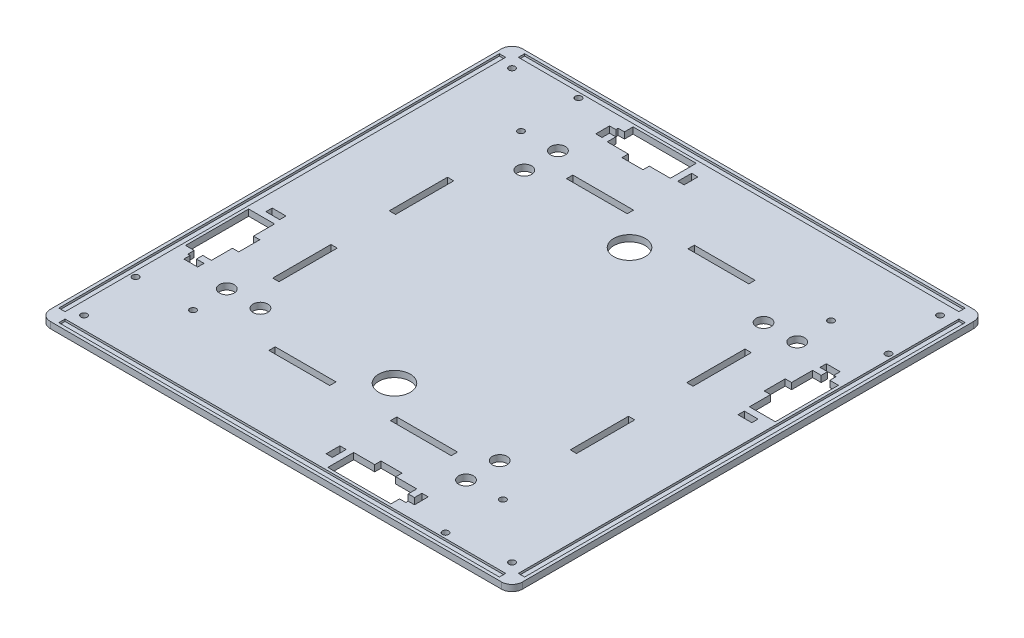
from build123d import *

# Parameters (mm, degrees)
SKETCH1_W           = 224.4
SKETCH1_H           = 224.4
SKETCH1_R           = 1.5
SKETCH1_W_2         = 28.88
SKETCH1_H_2         = 3
SKETCH1_W_3         = 3
SKETCH1_H_3         = 27.68
BOSS_EXTRUDE1_DEPTH = 3
FILLET1_R           = 5
SKETCH2_W           = 209.4
SKETCH2_H           = 3
SKETCH2_W_2         = 3
SKETCH2_H_2         = 209.4
CUT_EXTRUDE1_DEPTH  = 1
CUT_EXTRUDE3_DEPTH  = 4
CUT_EXTRUDE4_REACH  = 5
SKETCH4_R           = 1.5
SKETCH5_W           = 3
SKETCH5_H           = 6.55
SKETCH5_W_2         = 6.55
SKETCH5_H_2         = 3
CUT_EXTRUDE5_DEPTH  = 4
SKETCH6_R           = 3.5
CUT_EXTRUDE6_DEPTH  = 4
SKETCH13_R          = 7.5
CUT_EXTRUDE10_DEPTH = 4


with BuildPart() as part:
    # Sketch1 → Boss-Extrude1 (new body)
    with BuildSketch(Plane(origin=(0, 0, 0), x_dir=(1, 0, 0), z_dir=(0, 1, 0))):
        with Locations((112.2, 112.2)):
            Rectangle(SKETCH1_W, SKETCH1_H)
        with Locations((213.9, 10.5)):
            Circle(SKETCH1_R, mode=Mode.SUBTRACT)
        with Locations((213.9, 213.9)):
            Circle(SKETCH1_R, mode=Mode.SUBTRACT)
        with Locations((10.5, 10.5)):
            Circle(SKETCH1_R, mode=Mode.SUBTRACT)
        with Locations((10.5, 213.9)):
            Circle(SKETCH1_R, mode=Mode.SUBTRACT)
        with Locations((83.32, 41.5)):
            Rectangle(SKETCH1_W_2, SKETCH1_H_2, mode=Mode.SUBTRACT)
        with Locations((141.08, 41.5)):
            Rectangle(SKETCH1_W_2, SKETCH1_H_2, mode=Mode.SUBTRACT)
        with Locations((141.08, 182.9)):
            Rectangle(SKETCH1_W_2, SKETCH1_H_2, mode=Mode.SUBTRACT)
        with Locations((83.32, 182.9)):
            Rectangle(SKETCH1_W_2, SKETCH1_H_2, mode=Mode.SUBTRACT)
        with Locations((41.5, 84.52)):
            Rectangle(SKETCH1_W_3, SKETCH1_H_3, mode=Mode.SUBTRACT)
        with Locations((41.5, 139.88)):
            Rectangle(SKETCH1_W_3, SKETCH1_H_3, mode=Mode.SUBTRACT)
        with Locations((182.9, 139.88)):
            Rectangle(SKETCH1_W_3, SKETCH1_H_3, mode=Mode.SUBTRACT)
        with Locations((182.9, 84.52)):
            Rectangle(SKETCH1_W_3, SKETCH1_H_3, mode=Mode.SUBTRACT)
    extrude(amount=BOSS_EXTRUDE1_DEPTH)

    # Fillet1
    fillet1_edges = [part.edges().sort_by_distance(p)[0] for p in [
        (0, 1.5, -224.4),
        (224.4, 1.5, -224.4),
        (224.4, 1.5, 0),
        (0, 1.5, 0),
    ]]
    fillet(fillet1_edges, radius=FILLET1_R)

    # Sketch2 → Cut-Extrude1 (cut)
    with BuildSketch(Plane(origin=(0, 3, 0), x_dir=(1, 0, 0), z_dir=(0, 1, 0))):
        with Locations((112.2, 3)):
            Rectangle(SKETCH2_W, SKETCH2_H)
        with Locations((221.4, 112.2)):
            Rectangle(SKETCH2_W_2, SKETCH2_H_2)
        with Locations((112.2, 221.4)):
            Rectangle(SKETCH2_W, SKETCH2_H)
        with Locations((3, 112.2)):
            Rectangle(SKETCH2_W_2, SKETCH2_H_2)
    extrude(amount=-CUT_EXTRUDE1_DEPTH, mode=Mode.SUBTRACT)

    # Sketch3 → Cut-Extrude3 (cut, through all)
    with BuildSketch(Plane(origin=(0, 3, 0), x_dir=(1, 0, 0), z_dir=(0, 1, 0))):
        Polygon((131, 18.15), (131, 5.85), (161, 5.85), (161, 9.95), (164, 9.95), (164, 14.05), (161, 14.05), (161, 18.15), (151, 18.15), (151, 21.15), (141, 21.15), (141, 18.15), align=None)
        Polygon((18.15, 93.4), (5.85, 93.4), (5.85, 63.4), (9.95, 63.4), (9.95, 60.4), (14.05, 60.4), (14.05, 63.4), (18.15, 63.4), (18.15, 73.4), (21.15, 73.4), (21.15, 83.4), (18.15, 83.4), align=None)
        Polygon((93.4, 206.25), (93.4, 218.55), (63.4, 218.55), (63.4, 214.45), (60.4, 214.45), (60.4, 210.35), (63.4, 210.35), (63.4, 206.25), (73.4, 206.25), (73.4, 203.25), (83.4, 203.25), (83.4, 206.25), align=None)
        Polygon((206.25, 131), (218.55, 131), (218.55, 161), (214.45, 161), (214.45, 164), (210.35, 164), (210.35, 161), (206.25, 161), (206.25, 151), (203.25, 151), (203.25, 141), (206.25, 141), align=None)
    extrude(amount=-CUT_EXTRUDE3_DEPTH, mode=Mode.SUBTRACT)

    # Sketch4 → Cut-Extrude4 (cut, up to next)
    with BuildSketch(Plane(origin=(0, 3, 0), x_dir=(1, 0, 0), z_dir=(0, 1, 0)), mode=Mode.PRIVATE) as cut_extrude4_sk1:
        with Locations((38.54888627, 217.45)):
            Circle(SKETCH4_R)
    cut_extrude4_tool1 = extrude(cut_extrude4_sk1.sketch, amount=-CUT_EXTRUDE4_REACH, mode=Mode.PRIVATE) & part.part
    add(cut_extrude4_tool1.solids().sort_by_distance((38.548886, 3, -217.45))[0], mode=Mode.SUBTRACT)
    # Sketch4 → Cut-Extrude4 (cut, up to next)
    with BuildSketch(Plane(origin=(0, 3, 0), x_dir=(1, 0, 0), z_dir=(0, 1, 0)), mode=Mode.PRIVATE) as cut_extrude4_sk2:
        with Locations((38.54888627, 190.15)):
            Circle(SKETCH4_R)
    cut_extrude4_tool2 = extrude(cut_extrude4_sk2.sketch, amount=-CUT_EXTRUDE4_REACH, mode=Mode.PRIVATE) & part.part
    add(cut_extrude4_tool2.solids().sort_by_distance((38.548886, 3, -190.15))[0], mode=Mode.SUBTRACT)
    # Sketch4 → Cut-Extrude4 (cut, up to next)
    with BuildSketch(Plane(origin=(0, 3, 0), x_dir=(1, 0, 0), z_dir=(0, 1, 0)), mode=Mode.PRIVATE) as cut_extrude4_sk3:
        with Locations((217.45, 185.85111373)):
            Circle(SKETCH4_R)
    cut_extrude4_tool3 = extrude(cut_extrude4_sk3.sketch, amount=-CUT_EXTRUDE4_REACH, mode=Mode.PRIVATE) & part.part
    add(cut_extrude4_tool3.solids().sort_by_distance((217.45, 3, -185.851114))[0], mode=Mode.SUBTRACT)
    # Sketch4 → Cut-Extrude4 (cut, up to next)
    with BuildSketch(Plane(origin=(0, 3, 0), x_dir=(1, 0, 0), z_dir=(0, 1, 0)), mode=Mode.PRIVATE) as cut_extrude4_sk4:
        with Locations((190.15, 185.85111373)):
            Circle(SKETCH4_R)
    cut_extrude4_tool4 = extrude(cut_extrude4_sk4.sketch, amount=-CUT_EXTRUDE4_REACH, mode=Mode.PRIVATE) & part.part
    add(cut_extrude4_tool4.solids().sort_by_distance((190.15, 3, -185.851114))[0], mode=Mode.SUBTRACT)
    # Sketch4 → Cut-Extrude4 (cut, up to next)
    with BuildSketch(Plane(origin=(0, 3, 0), x_dir=(1, 0, 0), z_dir=(0, 1, 0)), mode=Mode.PRIVATE) as cut_extrude4_sk5:
        with Locations((185.85111373, 6.95)):
            Circle(SKETCH4_R)
    cut_extrude4_tool5 = extrude(cut_extrude4_sk5.sketch, amount=-CUT_EXTRUDE4_REACH, mode=Mode.PRIVATE) & part.part
    add(cut_extrude4_tool5.solids().sort_by_distance((185.851114, 3, -6.95))[0], mode=Mode.SUBTRACT)
    # Sketch4 → Cut-Extrude4 (cut, up to next)
    with BuildSketch(Plane(origin=(0, 3, 0), x_dir=(1, 0, 0), z_dir=(0, 1, 0)), mode=Mode.PRIVATE) as cut_extrude4_sk6:
        with Locations((185.85111373, 34.25)):
            Circle(SKETCH4_R)
    cut_extrude4_tool6 = extrude(cut_extrude4_sk6.sketch, amount=-CUT_EXTRUDE4_REACH, mode=Mode.PRIVATE) & part.part
    add(cut_extrude4_tool6.solids().sort_by_distance((185.851114, 3, -34.25))[0], mode=Mode.SUBTRACT)
    # Sketch4 → Cut-Extrude4 (cut, up to next)
    with BuildSketch(Plane(origin=(0, 3, 0), x_dir=(1, 0, 0), z_dir=(0, 1, 0)), mode=Mode.PRIVATE) as cut_extrude4_sk7:
        with Locations((6.95, 38.54888627)):
            Circle(SKETCH4_R)
    cut_extrude4_tool7 = extrude(cut_extrude4_sk7.sketch, amount=-CUT_EXTRUDE4_REACH, mode=Mode.PRIVATE) & part.part
    add(cut_extrude4_tool7.solids().sort_by_distance((6.95, 3, -38.548886))[0], mode=Mode.SUBTRACT)
    # Sketch4 → Cut-Extrude4 (cut, up to next)
    with BuildSketch(Plane(origin=(0, 3, 0), x_dir=(1, 0, 0), z_dir=(0, 1, 0)), mode=Mode.PRIVATE) as cut_extrude4_sk8:
        with Locations((34.25, 38.54888627)):
            Circle(SKETCH4_R)
    cut_extrude4_tool8 = extrude(cut_extrude4_sk8.sketch, amount=-CUT_EXTRUDE4_REACH, mode=Mode.PRIVATE) & part.part
    add(cut_extrude4_tool8.solids().sort_by_distance((34.25, 3, -38.548886))[0], mode=Mode.SUBTRACT)

    # Sketch5 → Cut-Extrude5 (cut, through all)
    with BuildSketch(Plane(origin=(0, 3, 0), x_dir=(1, 0, 0), z_dir=(0, 1, 0))):
        with Locations((126.5, 14.325)):
            Rectangle(SKETCH5_W, SKETCH5_H)
        with Locations((165.5, 14.325)):
            Rectangle(SKETCH5_W, SKETCH5_H)
        with Locations((14.325, 97.9)):
            Rectangle(SKETCH5_W_2, SKETCH5_H_2)
        with Locations((14.325, 58.9)):
            Rectangle(SKETCH5_W_2, SKETCH5_H_2)
        with Locations((97.9, 210.075)):
            Rectangle(SKETCH5_W, SKETCH5_H)
        with Locations((58.9, 210.075)):
            Rectangle(SKETCH5_W, SKETCH5_H)
        with Locations((210.075, 126.5)):
            Rectangle(SKETCH5_W_2, SKETCH5_H_2)
        with Locations((210.075, 165.5)):
            Rectangle(SKETCH5_W_2, SKETCH5_H_2)
    extrude(amount=-CUT_EXTRUDE5_DEPTH, mode=Mode.SUBTRACT)

    # Sketch6 → Cut-Extrude6 (cut, through all)
    with BuildSketch(Plane(origin=(0, 3, 0), x_dir=(1, 0, 0), z_dir=(0, 1, 0))):
        with Locations((169.05, 33.5)):
            Circle(SKETCH6_R)
        with Locations((169.05, 49.5)):
            Circle(SKETCH6_R)
        with Locations((33.5, 55.35)):
            Circle(SKETCH6_R)
        with Locations((49.5, 55.35)):
            Circle(SKETCH6_R)
        with Locations((55.35, 190.9)):
            Circle(SKETCH6_R)
        with Locations((55.35, 174.9)):
            Circle(SKETCH6_R)
        with Locations((190.9, 169.05)):
            Circle(SKETCH6_R)
        with Locations((174.9, 169.05)):
            Circle(SKETCH6_R)
    extrude(amount=-CUT_EXTRUDE6_DEPTH, mode=Mode.SUBTRACT)

    # Sketch13 → Cut-Extrude10 (cut, through all)
    with BuildSketch(Plane(origin=(0, 3, 0), x_dir=(1, 0, 0), z_dir=(0, 1, 0))):
        with Locations((112.2, 56.350000001)):
            Circle(SKETCH13_R)
        with Locations((112.2, 168.049999999)):
            Circle(SKETCH13_R)
    extrude(amount=-CUT_EXTRUDE10_DEPTH, mode=Mode.SUBTRACT)


solid = part.part
